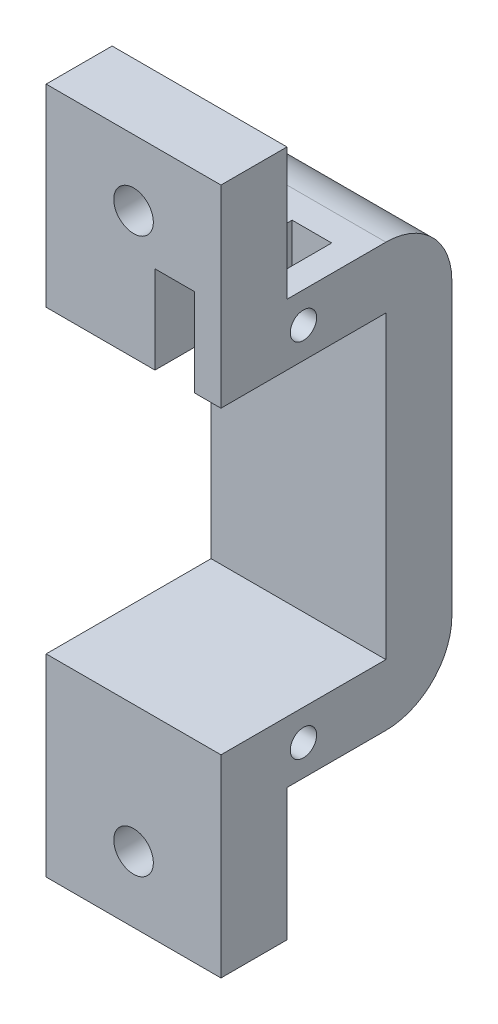
from build123d import *

# Parameters (mm, degrees)
ESBO_O1_W                = 13.25
ESBO_O1_H                = 12.5
RESSALTO_EXTRUS_O1_DEPTH = 4.65
ESBO_O2_W                = 13.25
ESBO_O2_H                = 32.05
RESSALTO_EXTRUS_O2_DEPTH = 5
ESBO_O3_W                = 13.25
ESBO_O3_H                = 4.65
RESSALTO_EXTRUS_O3_DEPTH = 12.5
ESBO_O4_W                = 13.25
ESBO_O4_H                = 5
RESSALTO_EXTRUS_O4_DEPTH = 10
ESBO_O5_W                = 13.25
ESBO_O5_H                = 5
RESSALTO_EXTRUS_O5_DEPTH = 10
ESBO_O6_R                = 1.5
CORTE_EXTRUS_O1_DEPTH    = 10
ESBO_O7_R                = 1
CORTE_EXTRUS_O2_DEPTH    = 14.25
ESBO_O8_R                = 1
CORTE_EXTRUS_O3_DEPTH    = 14.25
ESBO_O9_W                = 3
ESBO_O9_H                = 10.390977072
CORTE_EXTRUS_O4_DEPTH    = 10
ESBO_O10_W               = 3
ESBO_O10_H               = 2
CORTE_EXTRUS_O5_DEPTH    = 10
FILETE1_R                = 5
FILETE2_R                = 5


with BuildPart() as part:
    # Esboço1 → Ressalto-extrusão1 (new body)
    with BuildSketch(Plane(origin=(0, 0, 0), x_dir=(1, 0, 0), z_dir=(0, 1, 0))):
        with Locations((-15.112918198, -12.411797698)):
            Rectangle(ESBO_O1_W, ESBO_O1_H)
    extrude(amount=-RESSALTO_EXTRUS_O1_DEPTH)

    # Esboço2 → Ressalto-extrusão2 (add)
    with BuildSketch(Plane(origin=(0, 0, 6.161797698), x_dir=(-1, 0, 0), z_dir=(0, 0, -1))):
        with Locations((15.112918198, -16.025)):
            Rectangle(ESBO_O2_W, ESBO_O2_H)
    extrude(amount=RESSALTO_EXTRUS_O2_DEPTH)

    # Esboço3 → Ressalto-extrusão3 (add)
    with BuildSketch(Plane.XY.offset(6.161797698)):
        with Locations((-15.112918198, -29.725)):
            Rectangle(ESBO_O3_W, ESBO_O3_H)
    extrude(amount=RESSALTO_EXTRUS_O3_DEPTH)

    # Esboço4 → Ressalto-extrusão4 (add)
    with BuildSketch(Plane(origin=(0, -32.05, 0), x_dir=(-1, 0, 0), z_dir=(0, -1, 0))):
        with Locations((15.112918198, -16.161797698)):
            Rectangle(ESBO_O4_W, ESBO_O4_H)
    extrude(amount=RESSALTO_EXTRUS_O4_DEPTH)

    # Esboço5 → Ressalto-extrusão5 (add)
    with BuildSketch(Plane(origin=(0, 0, 0), x_dir=(1, 0, 0), z_dir=(0, 1, 0))):
        with Locations((-15.112918198, -16.161797698)):
            Rectangle(ESBO_O5_W, ESBO_O5_H)
    extrude(amount=RESSALTO_EXTRUS_O5_DEPTH)

    # Esboço6 → Corte-extrusão1 (cut)
    with BuildSketch(Plane(origin=(0, 0, 13.661797698), x_dir=(-1, 0, 0), z_dir=(0, 0, -1))):
        with Locations((15.112918198, 5)):
            Circle(ESBO_O6_R)
        with Locations((15.112918198, -37.05)):
            Circle(ESBO_O6_R)
    extrude(amount=-CORTE_EXTRUS_O1_DEPTH, mode=Mode.SUBTRACT)

    # Esboço7 → Corte-extrusão2 (cut, through all)
    with BuildSketch(Plane(origin=(-8.487918198, 0, 0), x_dir=(0, 0, -1), z_dir=(1, 0, 0))):
        with Locations((-12.411797698, -2.325)):
            Circle(ESBO_O7_R)
    extrude(amount=-CORTE_EXTRUS_O2_DEPTH, mode=Mode.SUBTRACT)

    # Esboço8 → Corte-extrusão3 (cut, through all)
    with BuildSketch(Plane(origin=(-8.487918198, 0, 0), x_dir=(0, 0, -1), z_dir=(1, 0, 0))):
        with Locations((-12.411797698, -29.725)):
            Circle(ESBO_O8_R)
    extrude(amount=-CORTE_EXTRUS_O3_DEPTH, mode=Mode.SUBTRACT)

    # Esboço9 → Corte-extrusão4 (cut)
    with BuildSketch(Plane(origin=(0, 0, 0), x_dir=(1, 0, 0), z_dir=(0, 1, 0))):
        with Locations((-11.987918198, -13.466309162)):
            Rectangle(ESBO_O9_W, ESBO_O9_H)
    extrude(amount=-CORTE_EXTRUS_O4_DEPTH, mode=Mode.SUBTRACT)

    # Esboço10 → Corte-extrusão5 (cut)
    with BuildSketch(Plane(origin=(0, 0, 13.661797698), x_dir=(-1, 0, 0), z_dir=(0, 0, -1))):
        with Locations((11.987918198, 1)):
            Rectangle(ESBO_O10_W, ESBO_O10_H)
    extrude(amount=-CORTE_EXTRUS_O5_DEPTH, mode=Mode.SUBTRACT)

    # Filete1
    filete1_edges = [part.edges().sort_by_distance(p)[0] for p in [
        (-15.112918198, 0, 1.161797698),
    ]]
    fillet(filete1_edges, radius=FILETE1_R)

    # Filete2
    filete2_edges = [part.edges().sort_by_distance(p)[0] for p in [
        (-15.112918198, -32.05, 1.161797698),
    ]]
    fillet(filete2_edges, radius=FILETE2_R)


solid = part.part
